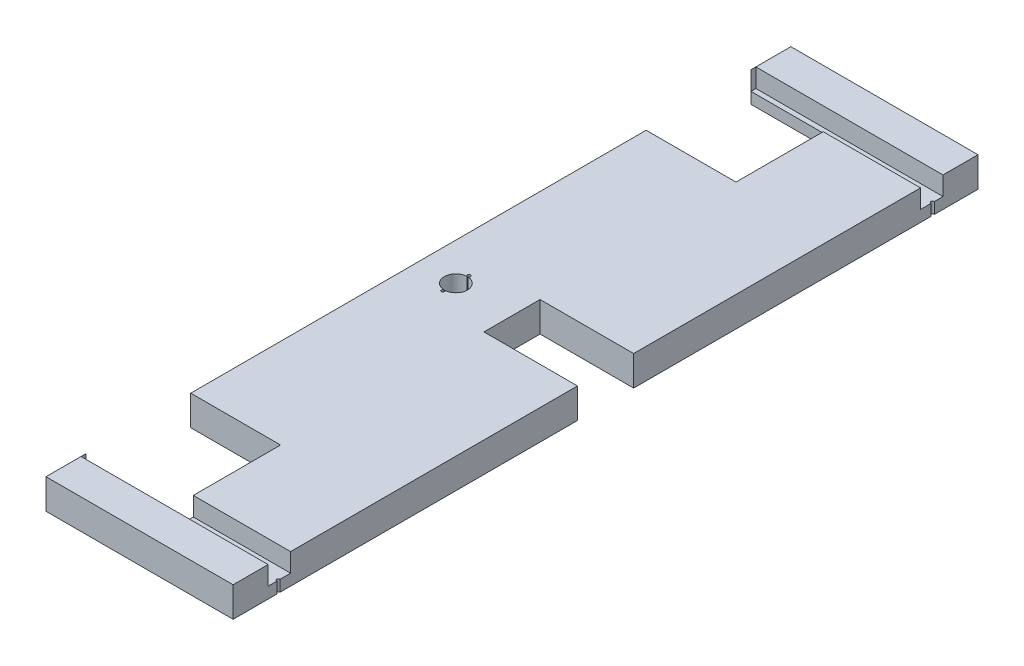
from build123d import *

# Parameters (mm, degrees)
SKETCH_R            = 2.25
BOSS_EXTRUDE3_DEPTH = 40
SKETCH1_W           = 249.949747468
SKETCH1_H           = 30
CUT_EXTRUDE1_DEPTH  = 25


with BuildPart() as part:
    # Sketch → Boss-Extrude3 (new body)
    with BuildSketch(Plane(origin=(0, 0, 0), x_dir=(1, 0, 0), z_dir=(0, 1, 0))):
        with BuildLine():
            Line((0, 191.780935723), (250, 191.780935723))
            Line((250, 191.780935723), (250, 133.455634672))
            ThreePointArc((250, 133.455634672), (247.75, 131.205634672), (250, 128.955634672))
            Line((250, 128.955634672), (250, -268.294365328))
            Line((250, -268.294365328), (125, -268.294365328))
            Line((125, -268.294365328), (125, -343.294365328))
            Line((125, -343.294365328), (250, -343.294365328))
            Line((250, -343.294365328), (250, -740.544365328))
            ThreePointArc((250, -740.544365328), (247.75, -742.794365328), (250, -745.044365328))
            Line((250, -745.044365328), (250, -803.36966638))
            Line((250, -803.36966638), (0, -803.36966638))
            Line((0, -803.36966638), (0, -750))
            Line((0, -750), (120, -750))
            Line((120, -750), (120, -610))
            Line((120, -610), (0, -610))
            Line((0, -610), (0, -1.588730657))
            Line((0, -1.588730657), (120, -1.588730657))
            Line((120, -1.588730657), (120, 138.411269343))
            Line((120, 138.411269343), (0, 138.411269343))
            Line((0, 138.411269343), (0, 191.780935723))
        make_face()
        with Locations((125, 131.205634672)):
            Circle(SKETCH_R, mode=Mode.SUBTRACT)
        with Locations((150, 131.205634672)):
            Circle(SKETCH_R, mode=Mode.SUBTRACT)
        with Locations((175, 131.205634672)):
            Circle(SKETCH_R, mode=Mode.SUBTRACT)
        with Locations((200, 131.205634672)):
            Circle(SKETCH_R, mode=Mode.SUBTRACT)
        with Locations((225, 131.205634672)):
            Circle(SKETCH_R, mode=Mode.SUBTRACT)
        with Locations((225, -742.794365328)):
            Circle(SKETCH_R, mode=Mode.SUBTRACT)
        with Locations((200, -742.794365328)):
            Circle(SKETCH_R, mode=Mode.SUBTRACT)
        with Locations((175, -742.794365328)):
            Circle(SKETCH_R, mode=Mode.SUBTRACT)
        with Locations((150, -742.794365328)):
            Circle(SKETCH_R, mode=Mode.SUBTRACT)
        with Locations((125, -742.794365328)):
            Circle(SKETCH_R, mode=Mode.SUBTRACT)
        with BuildLine():
            ThreePointArc((50.51221471, -290.298610608), (50, -286.225703188), (49.48778529, -290.298610608))
            ThreePointArc((49.48778529, -290.298610608), (34.497008873, -305.989414978), (49.877802923, -321.29810185))
            ThreePointArc((49.877802923, -321.29810185), (50, -325.294365328), (50.122197077, -321.29810185))
            ThreePointArc((50.122197077, -321.29810185), (65.502991127, -305.989414978), (50.51221471, -290.298610608))
        make_face(mode=Mode.SUBTRACT)
    extrude(amount=BOSS_EXTRUDE3_DEPTH)

    # Sketch1 → Cut-Extrude1 (cut)
    with BuildSketch(Plane(origin=(0, 40, 0), x_dir=(1, 0, 0), z_dir=(0, 1, 0))):
        with Locations((125.025126266, 130)):
            Rectangle(SKETCH1_W, SKETCH1_H)
        with Locations((125.025126266, -741.588730657)):
            Rectangle(SKETCH1_W, SKETCH1_H)
    extrude(amount=-CUT_EXTRUDE1_DEPTH, mode=Mode.SUBTRACT)


solid = part.part
